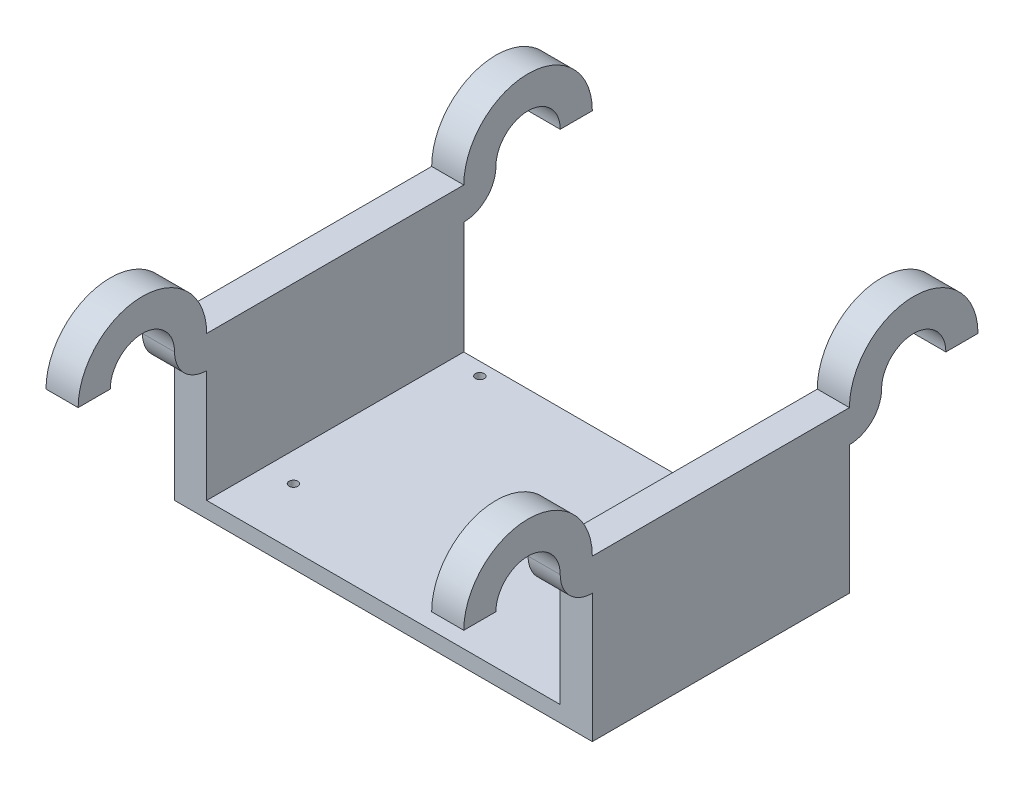
from build123d import *

# Parameters (mm, degrees)
SKETCH1_W               = 130
SKETCH1_H               = 80
BOSS_EXTRUDE1_DEPTH     = 5
SKETCH2_W               = 10
SKETCH2_H               = 80
BOSS_EXTRUDE2_DEPTH     = 45
SKETCH3_R               = 1.375
CUT_EXTRUDE1_DEPTH      = 46
CUT_EXTRUDE1_DEPTH_BACK = 6
BOSS_EXTRUDE3_DEPTH     = 10
BOSS_EXTRUDE4_DEPTH     = 10


with BuildPart() as part:
    # Sketch1 → Boss-Extrude1 (new body)
    with BuildSketch(Plane(origin=(0, 0, 0), x_dir=(1, 0, 0), z_dir=(0, 1, 0))):
        Rectangle(SKETCH1_W, SKETCH1_H)
    extrude(amount=BOSS_EXTRUDE1_DEPTH)

    # Sketch2 → Boss-Extrude2 (add)
    with BuildSketch(Plane(origin=(0, 5, 0), x_dir=(1, 0, 0), z_dir=(0, 1, 0))):
        with Locations((60, 0)):
            Rectangle(SKETCH2_W, SKETCH2_H)
        with Locations((-60, 0)):
            Rectangle(SKETCH2_W, SKETCH2_H)
    extrude(amount=BOSS_EXTRUDE2_DEPTH)

    # Sketch3 → Cut-Extrude1 (cut, two sides)
    with BuildSketch(Plane(origin=(0, 5, 0), x_dir=(1, 0, 0), z_dir=(0, 1, 0))) as cut_extrude1_sk:
        with Locations((-46, -22)):
            Circle(SKETCH3_R)
        with Locations((40, -22)):
            Circle(SKETCH3_R)
        with Locations((40, 36)):
            Circle(SKETCH3_R)
        with Locations((-46, 36)):
            Circle(SKETCH3_R)
    extrude(amount=CUT_EXTRUDE1_DEPTH, mode=Mode.SUBTRACT)
    extrude(cut_extrude1_sk.sketch, amount=-CUT_EXTRUDE1_DEPTH_BACK, mode=Mode.SUBTRACT)

    # Sketch4 → Boss-Extrude3 (add)
    with BuildSketch(Plane.ZY.offset(65)):
        with BuildLine():
            Line((-80, 50), (-70, 50))
            ThreePointArc((-70, 50), (-60, 60), (-50, 50))
            Line((-50, 50), (-40, 50))
            ThreePointArc((-40, 50), (-60, 70), (-80, 50))
        make_face()
        with BuildLine():
            Line((-40, 50), (-50, 50))
            ThreePointArc((-50, 50), (-47.071067812, 42.928932188), (-40, 40))
            Line((-40, 40), (-40, 50))
        make_face()
        with BuildLine():
            ThreePointArc((50, 50), (60, 60), (70, 50))
            Line((70, 50), (80, 50))
            ThreePointArc((80, 50), (60, 70), (40, 50))
            Line((40, 50), (50, 50))
        make_face()
        with BuildLine():
            ThreePointArc((40, 40), (47.071067812, 42.928932188), (50, 50))
            Line((50, 50), (40, 50))
            Line((40, 50), (40, 40))
        make_face()
    extrude(amount=-BOSS_EXTRUDE3_DEPTH)

    # Sketch5 → Boss-Extrude4 (add)
    with BuildSketch(Plane(origin=(65, 0, 0), x_dir=(0, 0, -1), z_dir=(1, 0, 0))):
        with BuildLine():
            ThreePointArc((-50, 50), (-47.071067812, 42.928932188), (-40, 40))
            Line((-40, 40), (-40, 50))
            ThreePointArc((-40, 50), (-60, 70), (-80, 50))
            Line((-80, 50), (-70, 50))
            ThreePointArc((-70, 50), (-60, 60), (-50, 50))
        make_face()
        with BuildLine():
            Line((40, 50), (40, 40))
            ThreePointArc((40, 40), (47.071067812, 42.928932188), (50, 50))
            ThreePointArc((50, 50), (60, 60), (70, 50))
            Line((70, 50), (80, 50))
            ThreePointArc((80, 50), (60, 70), (40, 50))
        make_face()
    extrude(amount=-BOSS_EXTRUDE4_DEPTH)


solid = part.part
